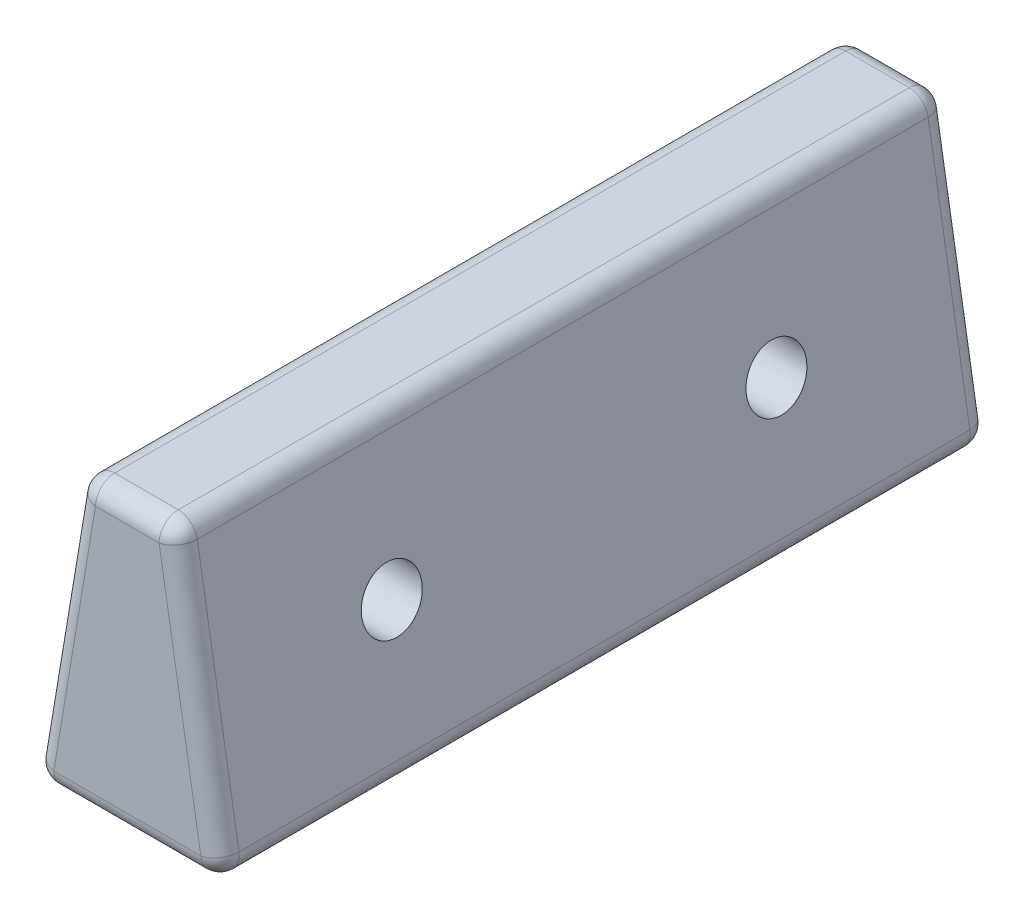
from build123d import *

# Parameters (mm, degrees)
BOSS_EXTRUDE1_DEPTH     = 50.8
FILLET1_R               = 2.54
SKETCH4_R               = 3.96875
CUT_EXTRUDE1_DEPTH      = 13.241630529
CUT_EXTRUDE1_DEPTH_BACK = 13.241630529


with BuildPart() as part:
    # Sketch3 → Boss-Extrude1 (new body, symmetric)
    with BuildSketch(Plane.XY):
        Polygon((-12.7, 0), (12.7, 0), (6.35, 38.1), (-6.35, 38.1), align=None)
    extrude(amount=BOSS_EXTRUDE1_DEPTH, both=True)

    # Fillet1
    fillet1_edges = [part.edges().sort_by_distance(p)[0] for p in [
        (0, 0, 50.8),
        (9.525, 19.05, 50.8),
        (0, 38.1, 50.8),
        (9.525, 19.05, -50.8),
        (0, 0, -50.8),
        (-9.525, 19.05, -50.8),
        (0, 38.1, -50.8),
        (-9.525, 19.05, 50.8),
        (6.35, 38.1, 0),
        (12.7, 0, 0),
        (-12.7, 0, 0),
        (-6.35, 38.1, 0),
    ]]
    fillet(fillet1_edges, radius=FILLET1_R)

    # Sketch4 → Cut-Extrude1 (cut, two sides)
    with BuildSketch(Plane(origin=(0, 0, 0), x_dir=(0, 0, -1), z_dir=(1, 0, 0))) as cut_extrude1_sk:
        with Locations((-25.4, 19.05)):
            Circle(SKETCH4_R)
        with Locations((25.4, 19.05)):
            Circle(SKETCH4_R)
    extrude(amount=CUT_EXTRUDE1_DEPTH, mode=Mode.SUBTRACT)
    extrude(cut_extrude1_sk.sketch, amount=-CUT_EXTRUDE1_DEPTH_BACK, mode=Mode.SUBTRACT)


solid = part.part
